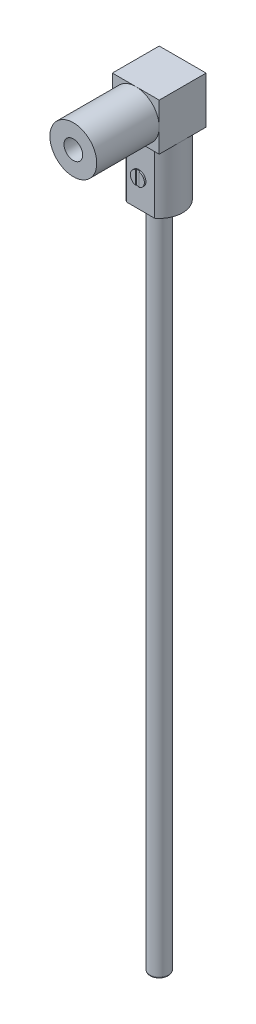
from build123d import *

# Parameters (mm, degrees)
SKETCH3_W           = 30
SKETCH3_H           = 30
BOSS_EXTRUDE1_DEPTH = 30
SKETCH4_R           = 15
SKETCH4_R_2         = 6
BOSS_EXTRUDE2_DEPTH = 40
SKETCH5_R           = 15
BOSS_EXTRUDE3_DEPTH = 40
CUT_EXTRUDE4_DEPTH  = 40
SKETCH7_R           = 3
BOSS_EXTRUDE4_DEPTH = 1
SKETCH8_R           = 4.5
BOSS_EXTRUDE5_DEPTH = 1
CUT_EXTRUDE5_DEPTH  = 0.5
SKETCH10_R          = 6
BOSS_EXTRUDE6_DEPTH = 428
FILLET1_R           = 1


with BuildPart() as part:
    # Sketch3 → Boss-Extrude1 (new body)
    with BuildSketch(Plane.XY):
        with Locations((15, 15)):
            Rectangle(SKETCH3_W, SKETCH3_H)
    extrude(amount=BOSS_EXTRUDE1_DEPTH)

    # Sketch4 → Boss-Extrude2 (add)
    with BuildSketch(Plane.XY.offset(30)):
        with Locations((15, 15)):
            Circle(SKETCH4_R)
        with Locations((15, 15)):
            Circle(SKETCH4_R_2, mode=Mode.SUBTRACT)
    extrude(amount=BOSS_EXTRUDE2_DEPTH)

    # Sketch5 → Boss-Extrude3 (add)
    with BuildSketch(Plane.XZ):
        with Locations((15, 15)):
            Circle(SKETCH5_R)
    extrude(amount=BOSS_EXTRUDE3_DEPTH)

    # Sketch6 → Cut-Extrude4 (cut)
    with BuildSketch(Plane.XZ.offset(40)):
        with BuildLine():
            Line((6, 27), (24, 27))
            ThreePointArc((24, 27), (15, 30), (6, 27))
        make_face()
    extrude(amount=-CUT_EXTRUDE4_DEPTH, mode=Mode.SUBTRACT)

    # Sketch7 → Boss-Extrude4 (add)
    with BuildSketch(Plane.XY.offset(27)):
        with Locations((15, -21.5)):
            Circle(SKETCH7_R)
    extrude(amount=BOSS_EXTRUDE4_DEPTH)

    # Sketch8 → Boss-Extrude5 (add)
    with BuildSketch(Plane.XY.offset(28)):
        with Locations((15, -21.5)):
            Circle(SKETCH8_R)
    extrude(amount=BOSS_EXTRUDE5_DEPTH)

    # Sketch9 → Cut-Extrude5 (cut)
    with BuildSketch(Plane.XY.offset(29)):
        with BuildLine():
            Line((16.2, -17.162950312), (16.2, -25.837049688))
            ThreePointArc((16.2, -25.837049688), (15, -26), (13.8, -25.837049688))
            Line((13.8, -25.837049688), (13.8, -17.162950312))
            ThreePointArc((13.8, -17.162950312), (15, -17), (16.2, -17.162950312))
        make_face()
    extrude(amount=-CUT_EXTRUDE5_DEPTH, mode=Mode.SUBTRACT)

    # Sketch10 → Boss-Extrude6 (add)
    with BuildSketch(Plane.XZ.offset(40)):
        with Locations((15, 15)):
            Circle(SKETCH10_R)
    extrude(amount=BOSS_EXTRUDE6_DEPTH)

    # Fillet1
    fillet1_edges = [part.edges().sort_by_distance(p)[0] for p in [
        (9, -468, 15),
    ]]
    fillet(fillet1_edges, radius=FILLET1_R)


solid = part.part
